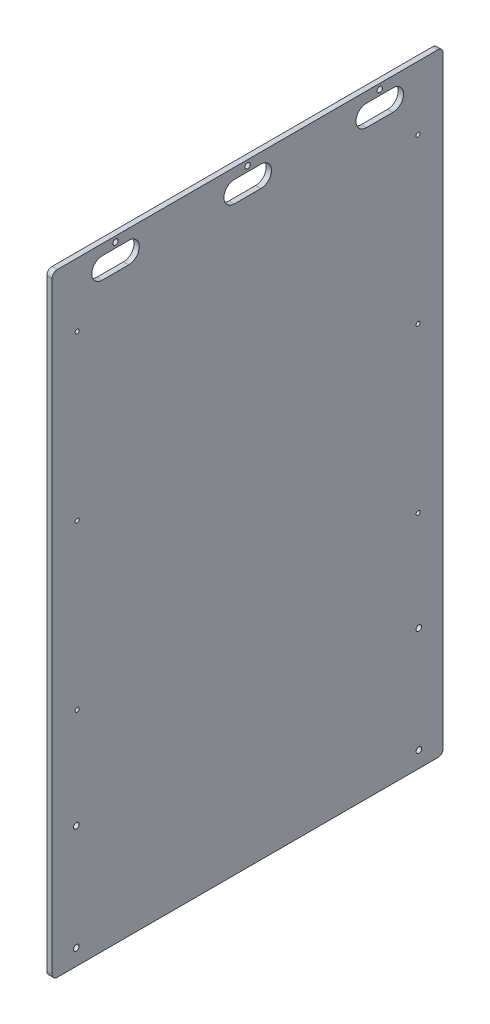
from build123d import *

# Parameters (mm, degrees)
SKETCH1_W                    = 469.9
SKETCH1_H                    = 736.6
BOSS_EXTRUDE1_DEPTH          = 6.35
F_10_0_1935_DIAMETER_HOLE1_D = 4.9149
H_0_266_DIAMETER_HOLE1_D     = 6.7564
CUT_EXTRUDE1_DEPTH           = 7.35
FILLET1_R                    = 6.35
E_0_25_DIAMETER_HOLE1_D      = 6.35


with BuildPart() as part:
    # Sketch1 → Boss-Extrude1 (new body)
    with BuildSketch(Plane(origin=(0, 0, 0), x_dir=(0, 0, -1), z_dir=(1, 0, 0))):
        Rectangle(SKETCH1_W, SKETCH1_H)
    extrude(amount=BOSS_EXTRUDE1_DEPTH)

    # #10 (0.1935) Diameter Hole1 (through all)
    with Locations(Plane(origin=(6.35, 0, 0), x_dir=(0, 0, -1), z_dir=(1, 0, 0))):
        with Locations((-204.7875, 291.846), (-204.7875, 94.996), (-204.7875, -101.854), (204.7875, 94.996), (204.7875, 291.846), (204.7875, -101.854)):
            Hole(F_10_0_1935_DIAMETER_HOLE1_D / 2)

    # H (0.266) Diameter Hole1 (through all)
    with Locations(Plane(origin=(6.35, 0, 0), x_dir=(0, 0, -1), z_dir=(1, 0, 0))):
        with Locations((-205.74, -221.996), (-205.74, -348.996), (205.74, -221.996), (205.74, -348.996)):
            Hole(H_0_266_DIAMETER_HOLE1_D / 2)

    # Sketch7 → Cut-Extrude1 (cut, through all)
    with BuildSketch(Plane(origin=(6.35, 0, 0), x_dir=(0, 0, -1), z_dir=(1, 0, 0))):
        with BuildLine():
            Line((-174.625, 355.6), (-142.875, 355.6))
            ThreePointArc((-142.875, 355.6), (-130.175, 342.9), (-142.875, 330.2))
            Line((-142.875, 330.2), (-174.625, 330.2))
            ThreePointArc((-174.625, 330.2), (-187.325, 342.9), (-174.625, 355.6))
        make_face()
        with BuildLine():
            Line((-15.875, 355.6), (15.875, 355.6))
            ThreePointArc((15.875, 355.6), (28.575, 342.9), (15.875, 330.2))
            Line((15.875, 330.2), (-15.875, 330.2))
            ThreePointArc((-15.875, 330.2), (-28.575, 342.9), (-15.875, 355.6))
        make_face()
        with BuildLine():
            Line((142.875, 355.6), (174.625, 355.6))
            ThreePointArc((174.625, 355.6), (187.325, 342.9), (174.625, 330.2))
            Line((174.625, 330.2), (142.875, 330.2))
            ThreePointArc((142.875, 330.2), (130.175, 342.9), (142.875, 355.6))
        make_face()
    extrude(amount=-CUT_EXTRUDE1_DEPTH, mode=Mode.SUBTRACT)

    # Fillet1
    fillet1_edges = [part.edges().sort_by_distance(p)[0] for p in [
        (3.175, -368.3, -234.95),
        (3.175, -368.3, 234.95),
        (3.175, 368.3, 234.95),
        (3.175, 368.3, -234.95),
    ]]
    fillet(fillet1_edges, radius=FILLET1_R)

    # E (0.25) Diameter Hole1 (through all)
    with Locations(Plane(origin=(6.35, 0, 0), x_dir=(0, 0, -1), z_dir=(1, 0, 0))):
        with Locations((-158.75, 361.95), (0, 361.95), (158.75, 361.95)):
            Hole(E_0_25_DIAMETER_HOLE1_D / 2)


solid = part.part
